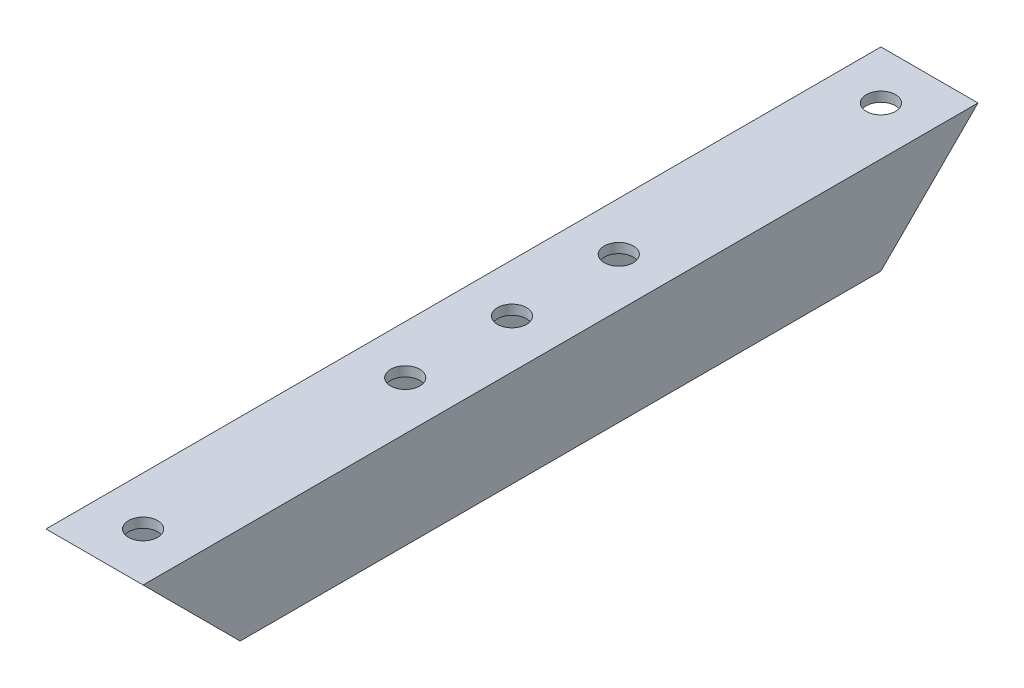
from build123d import *

# Parameters (mm, degrees)
SKETCH_1_W          = 10
SKETCH_1_H          = 10
SKETCH_1_W_2        = 8
SKETCH_1_H_2        = 8
EXTRUDE_1_DEPTH     = 86
SKETCH_2_R          = 1.5
CUT_EXTRUDE_1_DEPTH = 11
CUT_EXTRUDE_2_DEPTH = 10


with BuildPart() as part:
    # 草图1 → 拉伸-薄壁1 (new body)
    with BuildSketch(Plane.XY):
        Rectangle(SKETCH_1_W, SKETCH_1_H)
        Rectangle(SKETCH_1_W_2, SKETCH_1_H_2, mode=Mode.SUBTRACT)
    extrude(amount=EXTRUDE_1_DEPTH)

    # 草图2 → 切除-拉伸1 (cut, through all)
    with BuildSketch(Plane(origin=(0, 5, 0), x_dir=(1, 0, 0), z_dir=(0, 1, 0))):
        with Locations((0, -54)):
            Circle(SKETCH_2_R)
        with Locations((0, -32)):
            Circle(SKETCH_2_R)
        with Locations((0, -43)):
            Circle(SKETCH_2_R)
        with Locations((0, -81)):
            Circle(SKETCH_2_R)
        with Locations((0, -5)):
            Circle(SKETCH_2_R)
    extrude(amount=-CUT_EXTRUDE_1_DEPTH, mode=Mode.SUBTRACT)

    # 草图3 → 切除-拉伸2 (cut)
    with BuildSketch(Plane(origin=(5, 0, 0), x_dir=(0, 0, -1), z_dir=(1, 0, 0))):
        Polygon((-86, 5), (-76, -5), (-86, -5), align=None)
        Polygon((0, 5), (-10, -5), (0, -5), align=None)
    extrude(amount=-CUT_EXTRUDE_2_DEPTH, mode=Mode.SUBTRACT)


solid = part.part
